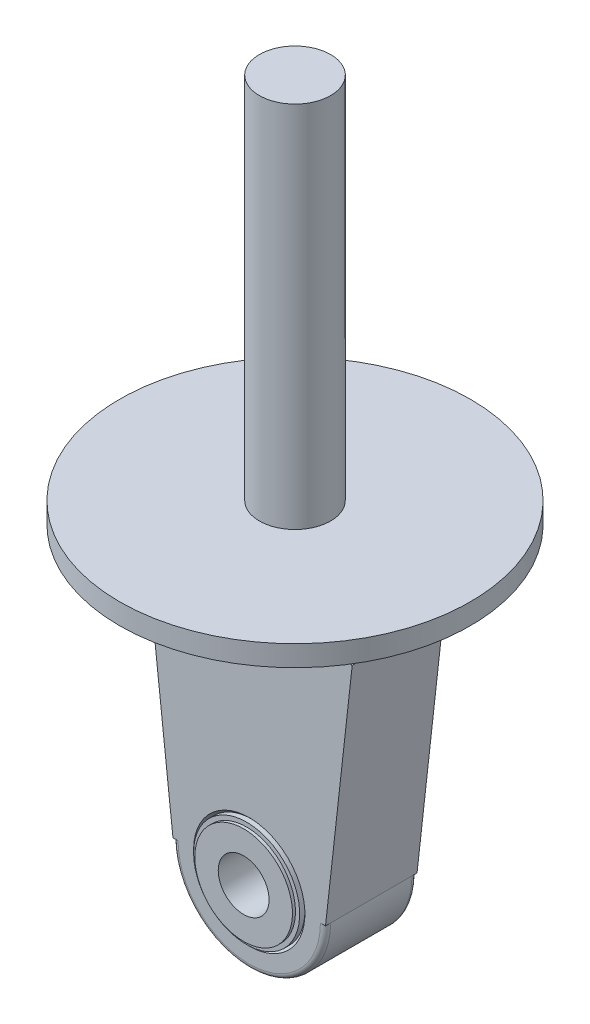
from build123d import *

# Parameters (mm, degrees)
EXTRUDE1_REACH             = 12.1
EXTRUDE1_DIRECTION_2_REACH = 12.1


with BuildPart() as part:
    # Sketch2 → Revolve1 (revolve)
    with BuildSketch(Plane(origin=(0, 0, 0), x_dir=(1, 0, 0), z_dir=(0, 1, 0))):
        with BuildLine():
            Line((5, 10.1), (5, -10.1))
            Line((5, -10.1), (9.6, -10.1))
            Line((9.6, -10.1), (9.6, -9.510239904))
            Line((9.6, -9.510239904), (10.433077185, -9.510239904))
            Line((10.433077185, -9.510239904), (10.433077185, -8.48743323))
            Line((10.433077185, -8.48743323), (10.945643955, -9))
            Line((10.945643955, -9), (14, -9))
            ThreePointArc((14, -9), (14.707106781, -8.707106781), (15, -8))
            Line((15, -8), (15, 8))
            ThreePointArc((15, 8), (14.707106781, 8.707106781), (14, 9))
            Line((14, 9), (10.945643955, 9))
            Line((10.945643955, 9), (10.433077185, 8.48743323))
            Line((10.433077185, 8.48743323), (10.433077185, 9.510239904))
            Line((10.433077185, 9.510239904), (9.6, 9.510239904))
            Line((9.6, 9.510239904), (9.6, 10.1))
            Line((9.6, 10.1), (5, 10.1))
        make_face()
    revolve(axis=Axis((0, 0, -9.945393457), (0, 0, 1)))

    # Extrude1: up to this face of the body (flat: up to its plane)
    extrude1_end = Plane(part.part.faces().sort_by_distance((-11.341623752, 0, 9))[0])
    # Sketch3 → Extrude1 (add, up to the picked face)
    with BuildSketch(Plane.XY, mode=Mode.PRIVATE) as extrude1_sk1:
        with BuildLine():
            Line((-20.25, 47), (-15, 0))
            Line((-15, 0), (-10.945643955, 0))
            ThreePointArc((-10.945643955, 0), (0, 10.945643955), (10.945643955, 0))
            Line((10.945643955, 0), (15, 0))
            Line((15, 0), (20.25, 47))
            Line((20.25, 47), (-20.25, 47))
        make_face()
    extrude1_tool1 = split(extrude(extrude1_sk1.sketch, amount=EXTRUDE1_REACH, mode=Mode.PRIVATE), bisect_by=extrude1_end, keep=Keep.BOTH, mode=Mode.PRIVATE)
    add(extrude1_tool1.solids().sort_by_distance((0, 27.232341, 0))[0])

    # Extrude1 direction 2: up to this face of the body (flat: up to its plane)
    extrude1_direction_2_end = Plane(part.part.faces().sort_by_distance((-13.604020203, 0, -9))[0])
    # Sketch3 → Extrude1 direction 2 (add, up to the picked face)
    with BuildSketch(Plane.XY, mode=Mode.PRIVATE) as extrude1_direction_2_sk1:
        with BuildLine():
            Line((-20.25, 47), (-15, 0))
            Line((-15, 0), (-10.945643955, 0))
            ThreePointArc((-10.945643955, 0), (0, 10.945643955), (10.945643955, 0))
            Line((10.945643955, 0), (15, 0))
            Line((15, 0), (20.25, 47))
            Line((20.25, 47), (-20.25, 47))
        make_face()
    extrude1_direction_2_tool1 = split(extrude(extrude1_direction_2_sk1.sketch, amount=-EXTRUDE1_DIRECTION_2_REACH, mode=Mode.PRIVATE), bisect_by=extrude1_direction_2_end, keep=Keep.BOTH, mode=Mode.PRIVATE)
    add(extrude1_direction_2_tool1.solids().sort_by_distance((0, 27.232341, 0))[0])

    # Sketch7 → Revolve2 (revolve)
    with BuildSketch(Plane.XY):
        Polygon((0, 47), (20.25, 47), (20.25, 53.100825313), (34.5, 56.36235646), (34.5, 60.45), (7, 60.45), (7, 132.908961398), (0, 132.908961398), align=None)
    revolve(axis=Axis((0, 0, 0), (0, 1, 0)))


solid = part.part
